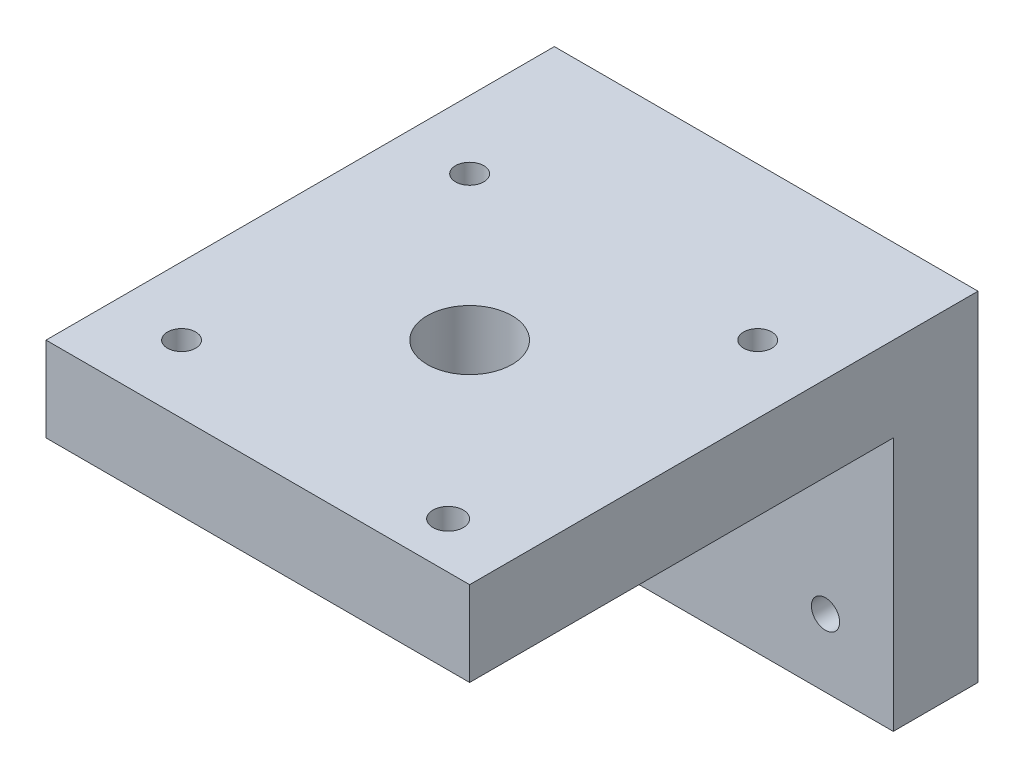
from build123d import *

# Parameters (mm, degrees)
SKETCH1_W           = 50
SKETCH1_H           = 50
SKETCH1_R           = 5
SKETCH1_R_2         = 1.666
SKETCH1_R_3         = 1.793902259
BOSS_EXTRUDE3_DEPTH = 10
SKETCH2_W           = 50
SKETCH2_H           = 10
BOSS_EXTRUDE4_DEPTH = 10
SKETCH3_W           = 50
SKETCH3_H           = 10
BOSS_EXTRUDE5_DEPTH = 30
SKETCH4_R           = 1.666
CUT_EXTRUDE1_DEPTH  = 30


with BuildPart() as part:
    # Sketch1 → Boss-Extrude3 (new body)
    with BuildSketch(Plane(origin=(0, 0, 0), x_dir=(1, 0, 0), z_dir=(0, 1, 0))):
        Rectangle(SKETCH1_W, SKETCH1_H)
        Circle(SKETCH1_R, mode=Mode.SUBTRACT)
        with Locations((-17, 17)):
            Circle(SKETCH1_R_2, mode=Mode.SUBTRACT)
        with Locations((17, 17)):
            Circle(SKETCH1_R_2, mode=Mode.SUBTRACT)
        with Locations((-17, -17)):
            Circle(SKETCH1_R_2, mode=Mode.SUBTRACT)
        with Locations((17, -19.536960904)):
            Circle(SKETCH1_R_3, mode=Mode.SUBTRACT)
    extrude(amount=BOSS_EXTRUDE3_DEPTH)

    # Sketch2 → Boss-Extrude4 (add)
    with BuildSketch(Plane(origin=(0, 0, -25), x_dir=(-1, 0, 0), z_dir=(0, 0, -1))):
        with Locations((0, 5)):
            Rectangle(SKETCH2_W, SKETCH2_H)
    extrude(amount=BOSS_EXTRUDE4_DEPTH)

    # Sketch3 → Boss-Extrude5 (add)
    with BuildSketch(Plane(origin=(0, 0, 0), x_dir=(-1, 0, 0), z_dir=(0, -1, 0))):
        with Locations((0, 30)):
            Rectangle(SKETCH3_W, SKETCH3_H)
    extrude(amount=BOSS_EXTRUDE5_DEPTH)

    # Sketch4 → Cut-Extrude1 (cut)
    with BuildSketch(Plane.XY.offset(-25)):
        with Locations((17, -22)):
            Circle(SKETCH4_R)
        with Locations((0, -10)):
            Circle(SKETCH4_R)
        with Locations((-17, -22)):
            Circle(SKETCH4_R)
    extrude(amount=-CUT_EXTRUDE1_DEPTH, mode=Mode.SUBTRACT)


solid = part.part
